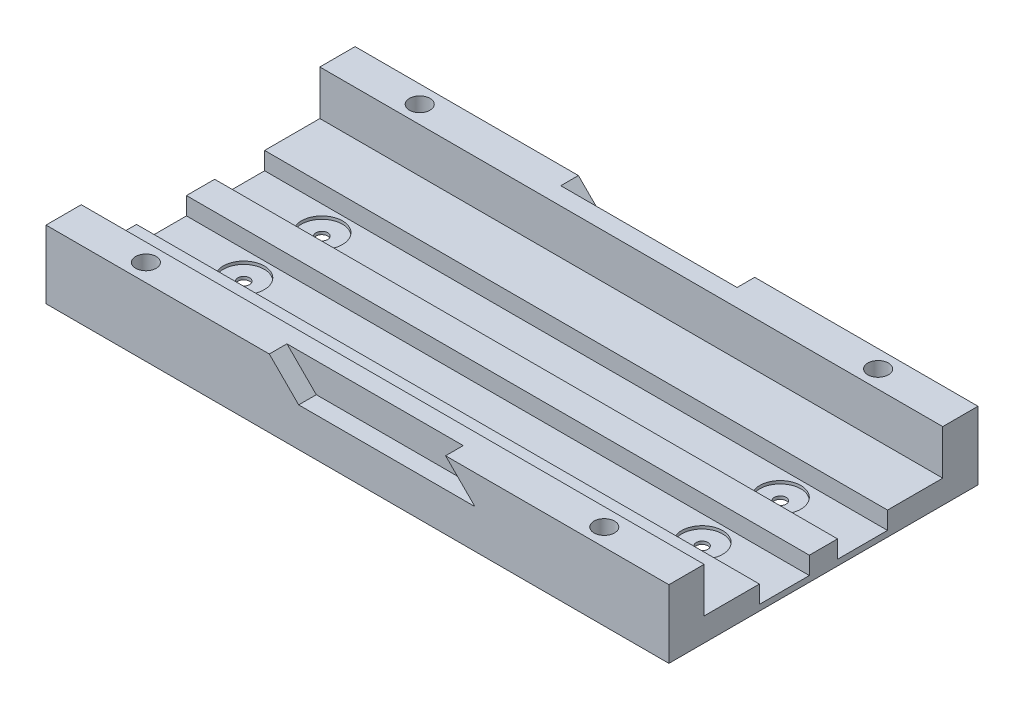
from build123d import *

# Parameters (mm, degrees)
SKETCH1_W           = 106
SKETCH1_H           = 6
SKETCH1_H_2         = 9.4
SKETCH1_H_3         = 8.5
SKETCH1_H_4         = 4.8
BOSS_EXTRUDE4_DEPTH = 4
SKETCH4_W           = 106
SKETCH4_H           = 8.5
CUT_EXTRUDE2_DEPTH  = 3
SKETCH5_W           = 106
SKETCH5_H           = 6
BOSS_EXTRUDE5_DEPTH = 7.6
SKETCH6_R           = 3.5
CUT_EXTRUDE3_DEPTH  = 0.5
SKETCH8_R           = 1
CUT_EXTRUDE4_DEPTH  = 20
SKETCH7_R           = 1
CUT_EXTRUDE5_DEPTH  = 20
SKETCH9_R           = 1
CUT_EXTRUDE6_DEPTH  = 20
SKETCH10_R          = 1.75
CUT_EXTRUDE7_DEPTH  = 20
SKETCH11_R          = 2.9
CUT_EXTRUDE8_DEPTH  = 4.5
CUT_EXTRUDE9_DEPTH  = 3
CUT_EXTRUDE10_DEPTH = 3


with BuildPart() as part:
    # Sketch1 → Boss-Extrude4 (new body)
    with BuildSketch(Plane(origin=(0, 0, 0), x_dir=(1, 0, 0), z_dir=(0, 1, 0))):
        with Locations((53, 20.9)):
            Rectangle(SKETCH1_W, SKETCH1_H)
        with Locations((53, 13.2)):
            Rectangle(SKETCH1_W, SKETCH1_H_2)
        with Locations((53, 4.25)):
            Rectangle(SKETCH1_W, SKETCH1_H_3)
        with Locations((53, -2.4)):
            Rectangle(SKETCH1_W, SKETCH1_H_4)
        with Locations((53, -9.05)):
            Rectangle(SKETCH1_W, SKETCH1_H_3)
        with Locations((53, -18)):
            Rectangle(SKETCH1_W, SKETCH1_H_2)
        with Locations((53, -25.7)):
            Rectangle(SKETCH1_W, SKETCH1_H)
    extrude(amount=BOSS_EXTRUDE4_DEPTH)

    # Sketch4 → Cut-Extrude2 (cut)
    with BuildSketch(Plane(origin=(0, 4, 0), x_dir=(1, 0, 0), z_dir=(0, 1, 0))):
        with Locations((53, 4.25)):
            Rectangle(SKETCH4_W, SKETCH4_H)
        with Locations((53, -9.05)):
            Rectangle(SKETCH4_W, SKETCH4_H)
    extrude(amount=-CUT_EXTRUDE2_DEPTH, mode=Mode.SUBTRACT)

    # Sketch5 → Boss-Extrude5 (add)
    with BuildSketch(Plane(origin=(0, 4, 0), x_dir=(1, 0, 0), z_dir=(0, 1, 0))):
        with Locations((53, 20.9)):
            Rectangle(SKETCH5_W, SKETCH5_H)
        with Locations((53, -25.7)):
            Rectangle(SKETCH5_W, SKETCH5_H)
    extrude(amount=BOSS_EXTRUDE5_DEPTH)

    # Sketch6 → Cut-Extrude3 (cut)
    with BuildSketch(Plane(origin=(0, 1, 0), x_dir=(1, 0, 0), z_dir=(0, 1, 0))):
        with Locations((92, -9.05)):
            Circle(SKETCH6_R)
        with Locations((14, -9.05)):
            Circle(SKETCH6_R)
        with Locations((92, 4.25)):
            Circle(SKETCH6_R)
        with Locations((14, 4.25)):
            Circle(SKETCH6_R)
    extrude(amount=-CUT_EXTRUDE3_DEPTH, mode=Mode.SUBTRACT)

    # Sketch8 → Cut-Extrude4 (cut)
    with BuildSketch(Plane(origin=(0, 0.5, 0), x_dir=(1, 0, 0), z_dir=(0, 1, 0))):
        with Locations((14, 4.25)):
            Circle(SKETCH8_R)
        with Locations((14, -9.05)):
            Circle(SKETCH8_R)
    extrude(amount=-CUT_EXTRUDE4_DEPTH, mode=Mode.SUBTRACT)

    # Sketch7 → Cut-Extrude5 (cut)
    with BuildSketch(Plane(origin=(0, 0.5, 0), x_dir=(1, 0, 0), z_dir=(0, 1, 0))):
        with Locations((92, 4.25)):
            Circle(SKETCH7_R)
    extrude(amount=-CUT_EXTRUDE5_DEPTH, mode=Mode.SUBTRACT)

    # Sketch9 → Cut-Extrude6 (cut)
    with BuildSketch(Plane(origin=(0, 0.5, 0), x_dir=(1, 0, 0), z_dir=(0, 1, 0))):
        with Locations((92, -9.05)):
            Circle(SKETCH9_R)
    extrude(amount=-CUT_EXTRUDE6_DEPTH, mode=Mode.SUBTRACT)

    # Sketch10 → Cut-Extrude7 (cut)
    with BuildSketch(Plane(origin=(0, 11.6, 0), x_dir=(1, 0, 0), z_dir=(0, 1, 0))):
        with Locations((92, 20.9)):
            Circle(SKETCH10_R)
        with Locations((14, 20.9)):
            Circle(SKETCH10_R)
        with Locations((92, -25.7)):
            Circle(SKETCH10_R)
        with Locations((14, -25.7)):
            Circle(SKETCH10_R)
    extrude(amount=-CUT_EXTRUDE7_DEPTH, mode=Mode.SUBTRACT)

    # Sketch11 → Cut-Extrude8 (cut)
    with BuildSketch(Plane(origin=(0, 0, 0), x_dir=(-1, 0, 0), z_dir=(0, -1, 0))):
        with Locations((-92, 20.9)):
            Circle(SKETCH11_R)
        with Locations((-92, -25.7)):
            Circle(SKETCH11_R)
        with Locations((-14, -25.7)):
            Circle(SKETCH11_R)
        with Locations((-14, 20.9)):
            Circle(SKETCH11_R)
    extrude(amount=-CUT_EXTRUDE8_DEPTH, mode=Mode.SUBTRACT)

    # Sketch12 → Cut-Extrude9 (cut)
    with BuildSketch(Plane(origin=(0, 0, -23.9), x_dir=(-1, 0, 0), z_dir=(0, 0, -1))):
        Polygon((-68, 11.6), (-73, 6.6), (-43, 6.6), (-38, 11.6), align=None)
    extrude(amount=-CUT_EXTRUDE9_DEPTH, mode=Mode.SUBTRACT)

    # Sketch13 → Cut-Extrude10 (cut)
    with BuildSketch(Plane.XY.offset(28.7)):
        Polygon((68, 11.6), (73, 6.6), (43, 6.6), (38, 11.6), align=None)
    extrude(amount=-CUT_EXTRUDE10_DEPTH, mode=Mode.SUBTRACT)


solid = part.part
